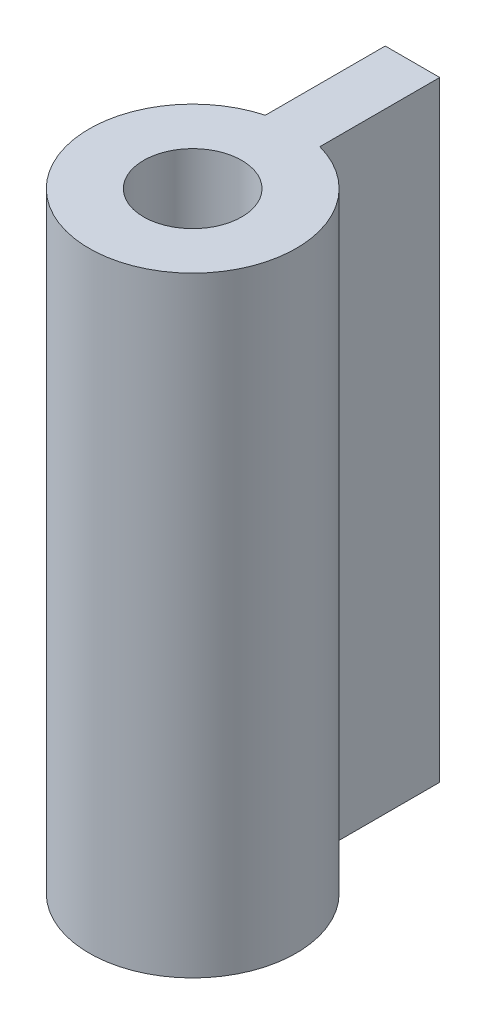
from build123d import *

# Parameters (mm, degrees)
SKETCH1_R           = 2.25
BOSS_EXTRUDE1_DEPTH = 28


with BuildPart() as part:
    # Sketch1 → Boss-Extrude1 (new body)
    with BuildSketch(Plane(origin=(0, 0, 0), x_dir=(1, 0, 0), z_dir=(0, 1, 0))):
        with BuildLine():
            Line((1.25, 10.082575695), (-1.25, 10.082575695))
            Line((-1.25, 10.082575695), (-1.25, 4.582575695))
            ThreePointArc((-1.25, 4.582575695), (0, 4.75), (1.25, 4.582575695))
            Line((1.25, 4.582575695), (1.25, 10.082575695))
        make_face()
        with BuildLine():
            Line((1.25, 4.582575695), (-1.25, 4.582575695))
            ThreePointArc((-1.25, 4.582575695), (-2.883140649, -3.774917218), (4.75, 0))
            ThreePointArc((4.75, 0), (3.774917218, 2.883140649), (1.25, 4.582575695))
        make_face()
        Circle(SKETCH1_R, mode=Mode.SUBTRACT)
        with BuildLine():
            ThreePointArc((1.25, 4.582575695), (0, 4.75), (-1.25, 4.582575695))
            Line((-1.25, 4.582575695), (1.25, 4.582575695))
        make_face()
    extrude(amount=BOSS_EXTRUDE1_DEPTH)


solid = part.part
